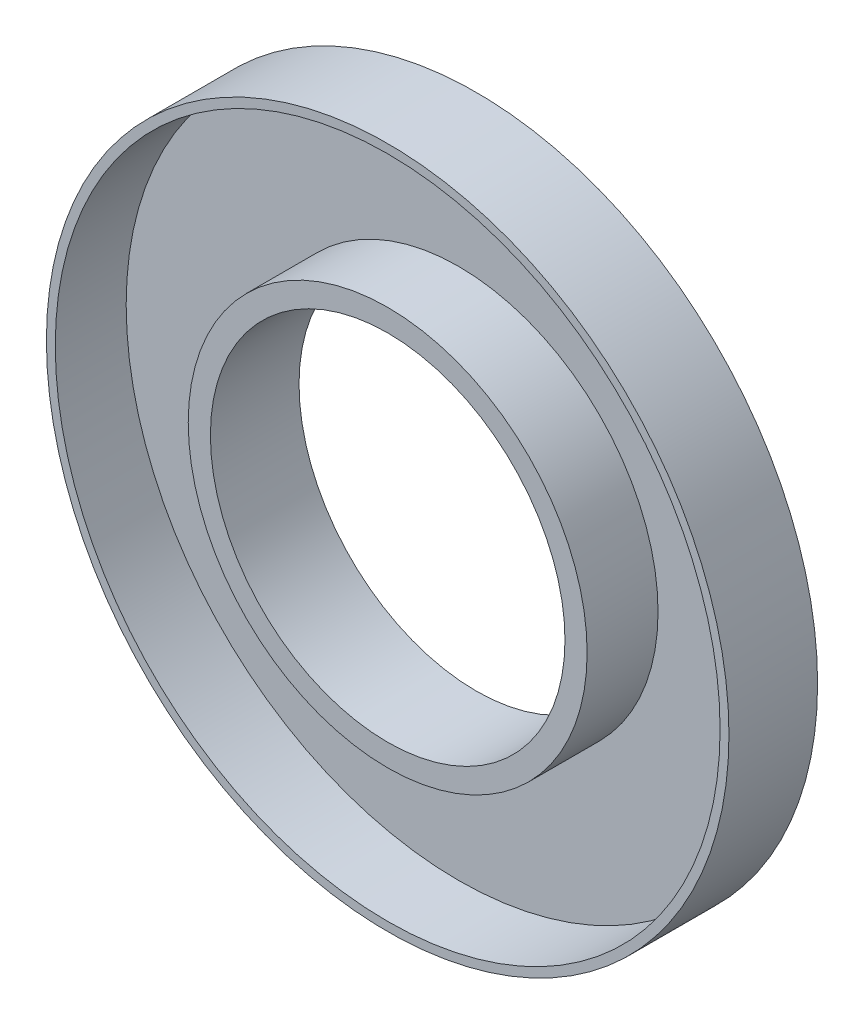
from build123d import *

# Parameters (mm, degrees)
SKETCH1_R           = 19.25
BOSS_EXTRUDE1_DEPTH = 1
SKETCH2_R           = 11.25
SKETCH2_R_2         = 10
BOSS_EXTRUDE2_DEPTH = 4
SKETCH3_R           = 19.25
SKETCH3_R_2         = 18.75
BOSS_EXTRUDE3_DEPTH = 4
SKETCH5_R           = 10
CUT_EXTRUDE1_DEPTH  = 5


with BuildPart() as part:
    # Sketch1 → Boss-Extrude1 (new body)
    with BuildSketch(Plane.XY):
        Circle(SKETCH1_R)
    extrude(amount=BOSS_EXTRUDE1_DEPTH)

    # Sketch2 → Boss-Extrude2 (add)
    with BuildSketch(Plane.XY.offset(1)):
        Circle(SKETCH2_R)
        Circle(SKETCH2_R_2, mode=Mode.SUBTRACT)
    extrude(amount=BOSS_EXTRUDE2_DEPTH)

    # Sketch3 → Boss-Extrude3 (add)
    with BuildSketch(Plane.XY.offset(1)):
        Circle(SKETCH3_R)
        Circle(SKETCH3_R_2, mode=Mode.SUBTRACT)
    extrude(amount=BOSS_EXTRUDE3_DEPTH)

    # Sketch5 → Cut-Extrude1 (cut)
    with BuildSketch(Plane.XY.offset(1)):
        Circle(SKETCH5_R)
    extrude(amount=-CUT_EXTRUDE1_DEPTH, mode=Mode.SUBTRACT)


solid = part.part
